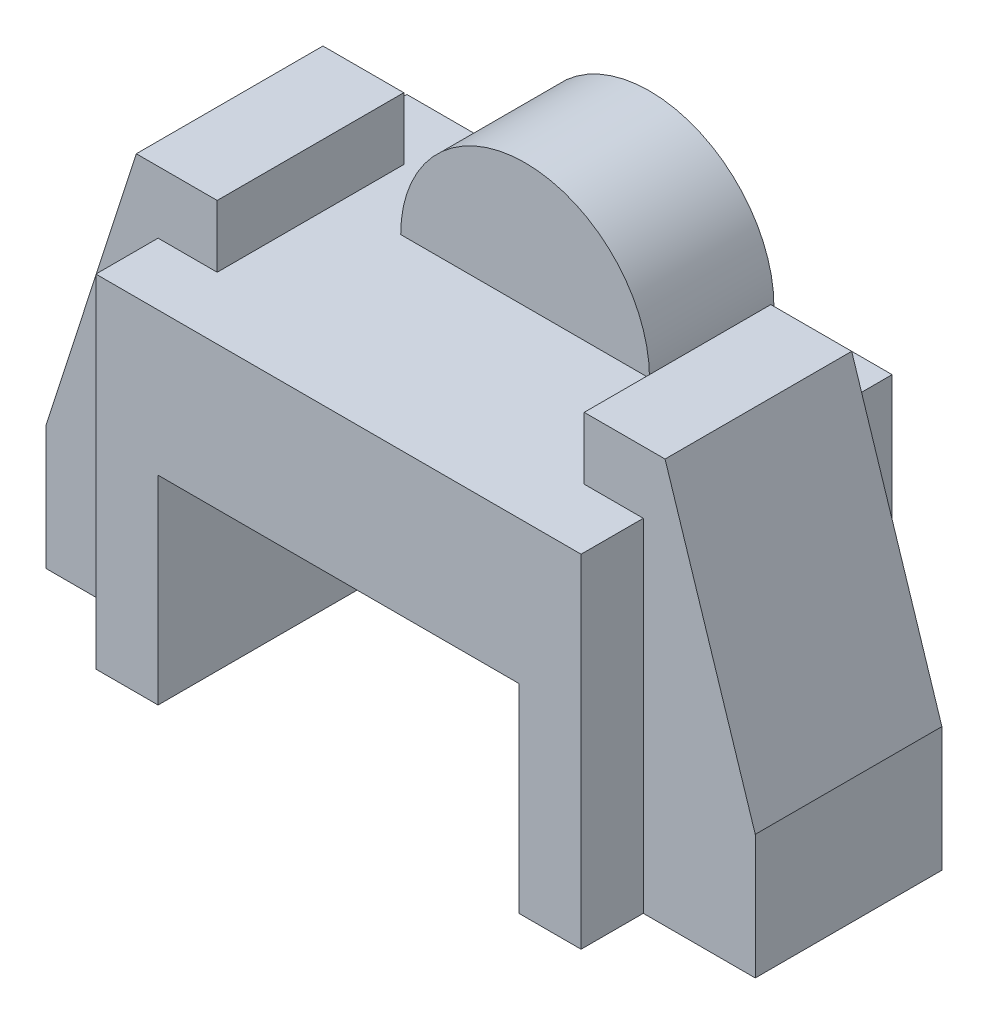
from build123d import *

# Parameters (mm, degrees)
SKETCH15_W           = 78
SKETCH15_H           = 55
BOSS_EXTRUDE9_DEPTH  = 50
SKETCH16_W           = 58
SKETCH16_H           = 32
CUT_EXTRUDE3_DEPTH   = 50
SKETCH17_R           = 20
BOSS_EXTRUDE10_DEPTH = 20
BOSS_EXTRUDE11_DEPTH = 15


with BuildPart() as part:
    # Sketch15 → Boss-Extrude9 (new body)
    with BuildSketch(Plane.XY):
        with Locations((39, 27.5)):
            Rectangle(SKETCH15_W, SKETCH15_H)
    extrude(amount=BOSS_EXTRUDE9_DEPTH)

    # Sketch16 → Cut-Extrude3 (cut)
    with BuildSketch(Plane.XY.offset(50)):
        with Locations((39, 16)):
            Rectangle(SKETCH16_W, SKETCH16_H)
    extrude(amount=-CUT_EXTRUDE3_DEPTH, mode=Mode.SUBTRACT)

    # Sketch17 → Boss-Extrude10 (add)
    with BuildSketch(Plane(origin=(0, 0, 0), x_dir=(-1, 0, 0), z_dir=(0, 0, -1))):
        with Locations((-39, 55)):
            Circle(SKETCH17_R)
    extrude(amount=-BOSS_EXTRUDE10_DEPTH)

    # Sketch21 → Boss-Extrude11 (add, symmetric)
    with BuildSketch(Plane(origin=(0, 0, 25), x_dir=(-1, 0, 0), z_dir=(0, 0, -1))):
        Polygon((-9.5, 0), (18, 0), (18, 20), (3.5, 65), (-9.5, 65), align=None)
    boss_extrude11 = extrude(amount=BOSS_EXTRUDE11_DEPTH, both=True)

    # Mirror4: Boss-Extrude11 across plane
    add(boss_extrude11.mirror(Plane.ZY.offset(-39)))


solid = part.part
